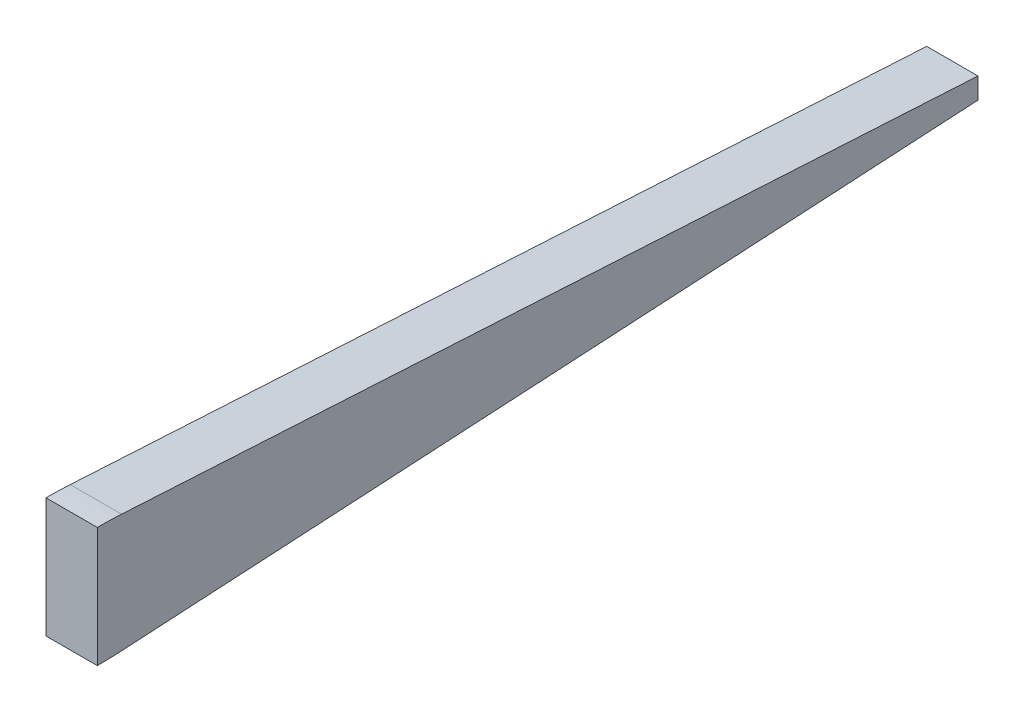
from build123d import *

# Parameters (mm, degrees)
EXTRUDE1_DEPTH = 6


with BuildPart() as part:
    # Sketch1 → Extrude1 (new body, symmetric)
    with BuildSketch(Plane(origin=(0, 0, 0), x_dir=(0, 0, -1), z_dir=(1, 0, 0))):
        with BuildLine():
            Line((105.67734259, 13.838708831), (302.152337132, 2.666129904))
            Line((302.152337132, 2.666129904), (306, 2.447331999))
            Line((306, 2.447331999), (306, 0))
            Line((306, 0), (100, 0))
            Line((100, 0), (100, 14))
            ThreePointArc((100, 14), (102.839816619, 13.959669075), (105.67734259, 13.838708831))
        make_face()
    extrude1 = extrude(amount=EXTRUDE1_DEPTH, both=True)

    # Mirror1: Extrude1 across plane
    add(extrude1.mirror(Plane(origin=(6, 0, -306), x_dir=(0, 0, 1), z_dir=(0, 1, 0))))


solid = part.part
